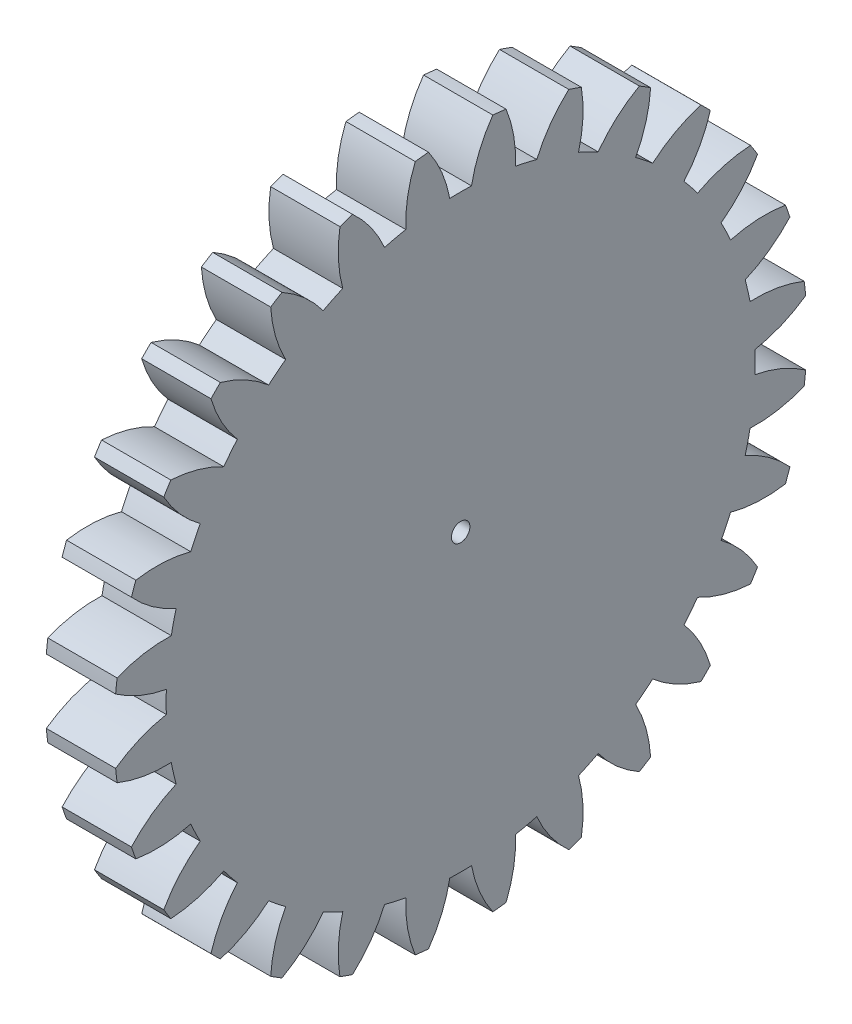
from build123d import *

# Parameters (mm, degrees)
BASPROSKE_W     = 3
BASPROSKE_H     = 15
TOOTHCUT_DEPTH  = 22.424285286
TEETHCUTS_COUNT = 28
TEETHCUTS_ANGLE = 347.142857143
BORSKE_R        = 0.4
BORE_DEPTH      = 50.0000508


with BuildPart() as part:
    # BasProSke → Base-Revolve (revolve)
    with BuildSketch(Plane(origin=(0, 0, 0), x_dir=(1, 0, 0), z_dir=(0, 1, 0)), mode=Mode.PRIVATE) as base_revolve_sk:
        with Locations((1.5, 7.5)):
            Rectangle(BASPROSKE_W, BASPROSKE_H)
    revolve(base_revolve_sk.sketch.rotate(Axis((-10, 0, 0), (1, 0, 0)), 180), axis=Axis((-10, 0, 0), (1, 0, 0)))

    # TooCutSke → ToothCut (cut, through all)
    with BuildSketch(Plane(origin=(0, 0, 0), x_dir=(0, 0, -1), z_dir=(1, 0, 0))):
        with BuildLine():
            ThreePointArc((0.471336039, 12.740284272), (0, 12.749), (-0.471336039, 12.740284272))
            ThreePointArc((-0.471336039, 12.740284272), (-0.81983923, 13.900763331), (-1.409805137, 14.959114099))
            ThreePointArc((-1.409805137, 14.959114099), (0, 15.0254), (1.409805137, 14.959114099))
            ThreePointArc((1.409805137, 14.959114099), (0.81983923, 13.900763331), (0.471336039, 12.740284272))
        make_face()
    toothcut = extrude(amount=TOOTHCUT_DEPTH, mode=Mode.SUBTRACT)

    # TeethCuts: ToothCut ×28 about axis
    teethcuts_axis = Axis((-10, 0, 0), (1, 0, 0))
    for i in range(1, TEETHCUTS_COUNT):
        add(toothcut.rotate(teethcuts_axis, i * TEETHCUTS_ANGLE / (TEETHCUTS_COUNT - 1)), mode=Mode.SUBTRACT)

    # BorSke → Bore (cut, symmetric)
    with BuildSketch(Plane(origin=(0, 0, 0), x_dir=(0, 0, -1), z_dir=(1, 0, 0))):
        with Locations(Location((0, 0, 0), (0, 0, 180))):
            Circle(BORSKE_R)
    extrude(amount=BORE_DEPTH, both=True, mode=Mode.SUBTRACT)


solid = part.part
